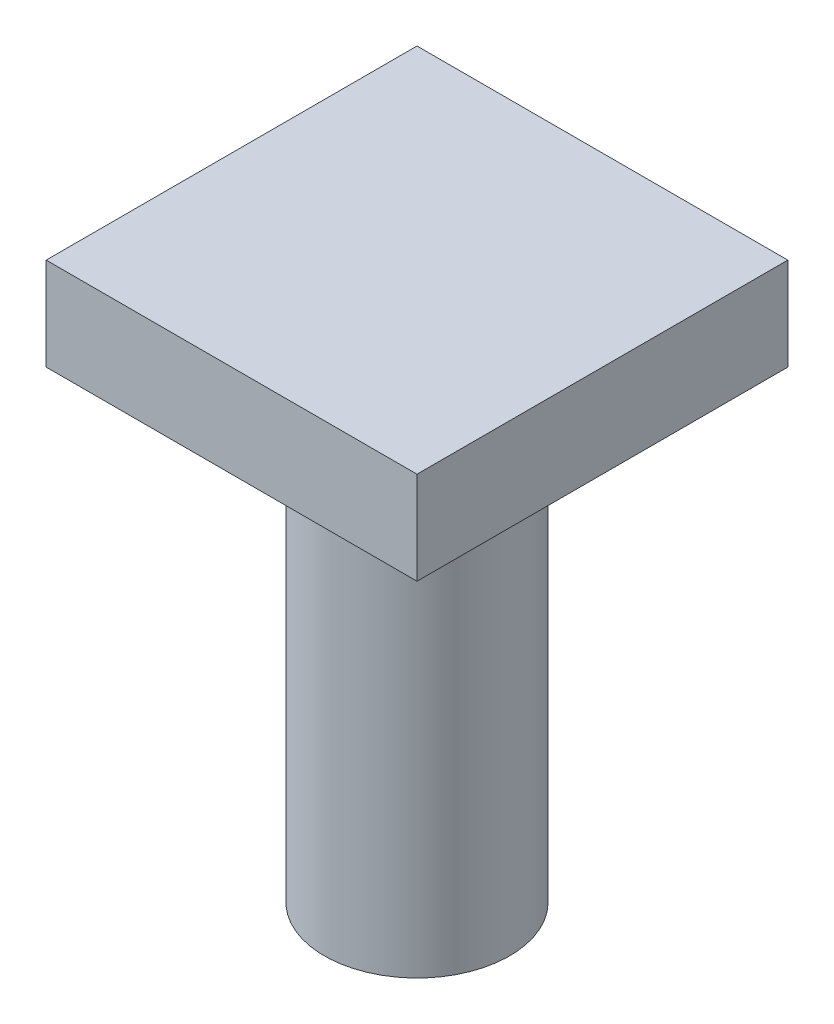
from build123d import *

# Parameters (mm, degrees)
SKETCH_1_W          = 20
SKETCH_1_H          = 20
EXTRUDE_1_DEPTH     = 30
SKETCH_3_W          = 20
SKETCH_3_H          = 20
SKETCH_3_R          = 5
CUT_EXTRUDE_1_DEPTH = 25


with BuildPart() as part:
    # Эскиз1 → Бобышка-Вытянуть1 (new body)
    with BuildSketch(Plane(origin=(0, 0, 0), x_dir=(1, 0, 0), z_dir=(0, 1, 0))):
        Rectangle(SKETCH_1_W, SKETCH_1_H)
    extrude(amount=EXTRUDE_1_DEPTH)

    # Эскиз3 → Вырез-Вытянуть1 (cut)
    with BuildSketch(Plane.XZ):
        Rectangle(SKETCH_3_W, SKETCH_3_H)
        Circle(SKETCH_3_R, mode=Mode.SUBTRACT)
    extrude(amount=-CUT_EXTRUDE_1_DEPTH, mode=Mode.SUBTRACT)


solid = part.part
